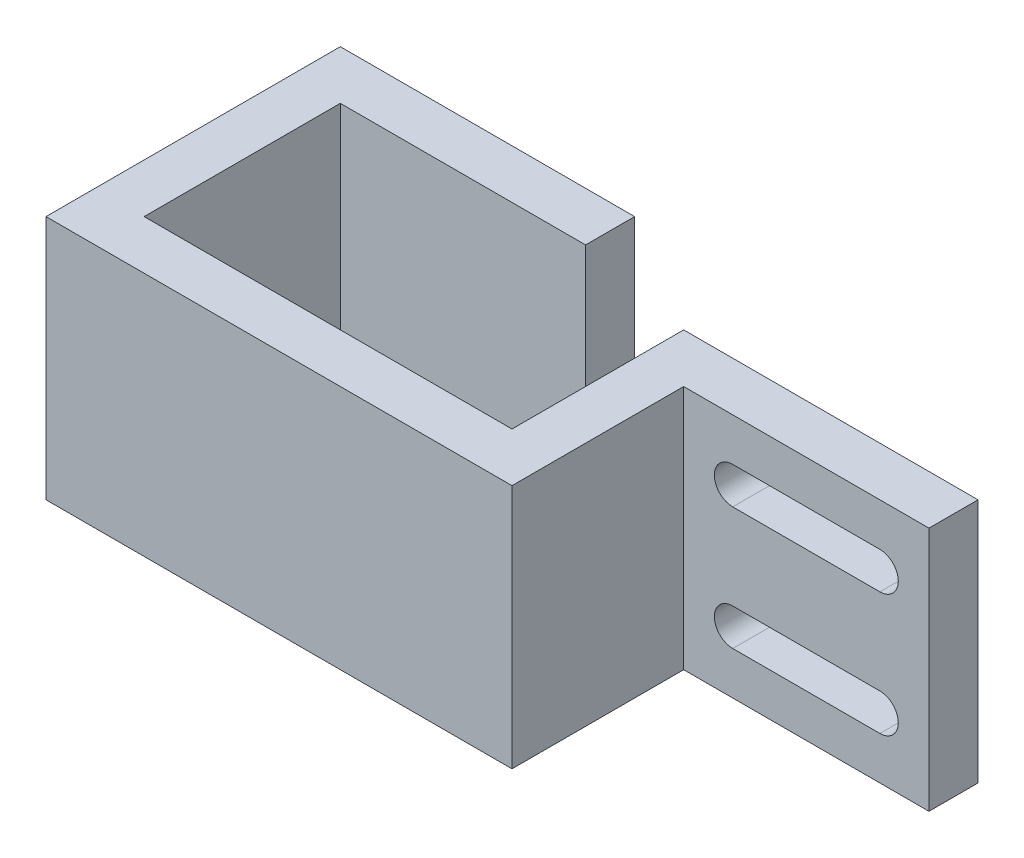
from build123d import *

# Parameters (mm, degrees)
SALIENTE_EXTRUIR1_DEPTH = 20
CORTAR_EXTRUIR1_DEPTH   = 20
CROQUIS3_W              = 4
CROQUIS3_H              = 20
SALIENTE_EXTRUIR2_DEPTH = 20


with BuildPart() as part:
    # Croquis1 → Saliente-Extruir1 (new body)
    with BuildSketch(Plane(origin=(0, 0, 0), x_dir=(1, 0, 0), z_dir=(0, 1, 0))):
        Polygon((-19, 24), (-15, 24), (-15, 4), (15, 4), (15, 18), (39, 18), (39, 14), (19, 14), (19, 0), (-19, 0), align=None)
    extrude(amount=SALIENTE_EXTRUIR1_DEPTH)

    # Croquis2 → Cortar-Extruir1 (cut)
    with BuildSketch(Plane.XY.offset(-14)):
        with BuildLine():
            Line((35, 16.5), (23, 16.5))
            ThreePointArc((23, 16.5), (21.5, 15), (23, 13.5))
            Line((23, 13.5), (35, 13.5))
            ThreePointArc((35, 13.5), (36.5, 15), (35, 16.5))
        make_face()
        with BuildLine():
            Line((35, 3.5), (23, 3.5))
            ThreePointArc((23, 3.5), (21.5, 5), (23, 6.5))
            Line((23, 6.5), (35, 6.5))
            ThreePointArc((35, 6.5), (36.5, 5), (35, 3.5))
        make_face()
    extrude(amount=-CORTAR_EXTRUIR1_DEPTH, mode=Mode.SUBTRACT)

    # Croquis3 → Saliente-Extruir2 (add)
    with BuildSketch(Plane(origin=(-15, 0, 0), x_dir=(0, 0, -1), z_dir=(1, 0, 0))):
        with Locations((22, 10)):
            Rectangle(CROQUIS3_W, CROQUIS3_H)
    extrude(amount=SALIENTE_EXTRUIR2_DEPTH)


solid = part.part
